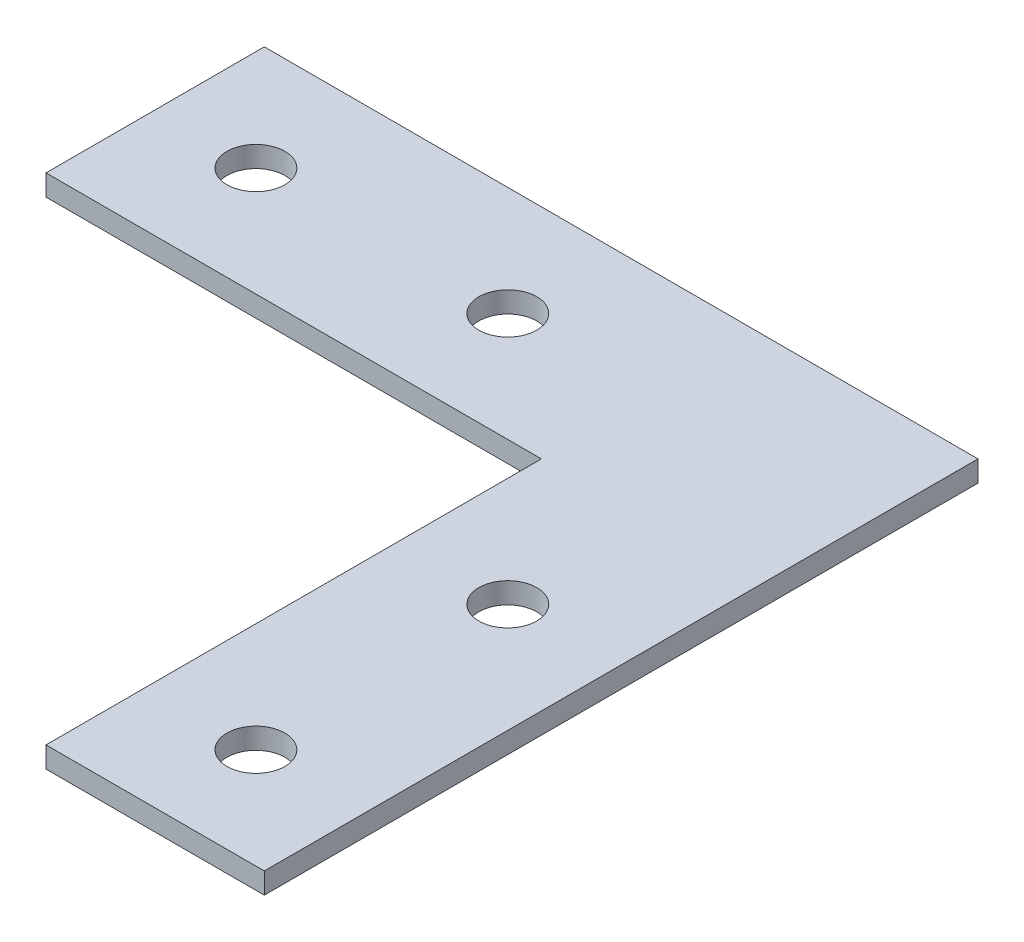
from build123d import *

# Parameters (mm, degrees)
SKETCH_1_R      = 3.45
EXTRUDE_1_DEPTH = 2.5


with BuildPart() as part:
    # 草图1 → 凸台-拉伸1 (new body)
    with BuildSketch(Plane(origin=(0, 0, 0), x_dir=(1, 0, 0), z_dir=(0, 1, 0))):
        Polygon((0, 0), (0, -59), (26, -59), (26, 26), (-59, 26), (-59, 0), align=None)
        with Locations((-47, 13)):
            Circle(SKETCH_1_R, mode=Mode.SUBTRACT)
        with Locations((-17, 13)):
            Circle(SKETCH_1_R, mode=Mode.SUBTRACT)
        with Locations((13, -47)):
            Circle(SKETCH_1_R, mode=Mode.SUBTRACT)
        with Locations((13, -17)):
            Circle(SKETCH_1_R, mode=Mode.SUBTRACT)
    extrude(amount=EXTRUDE_1_DEPTH)


solid = part.part
